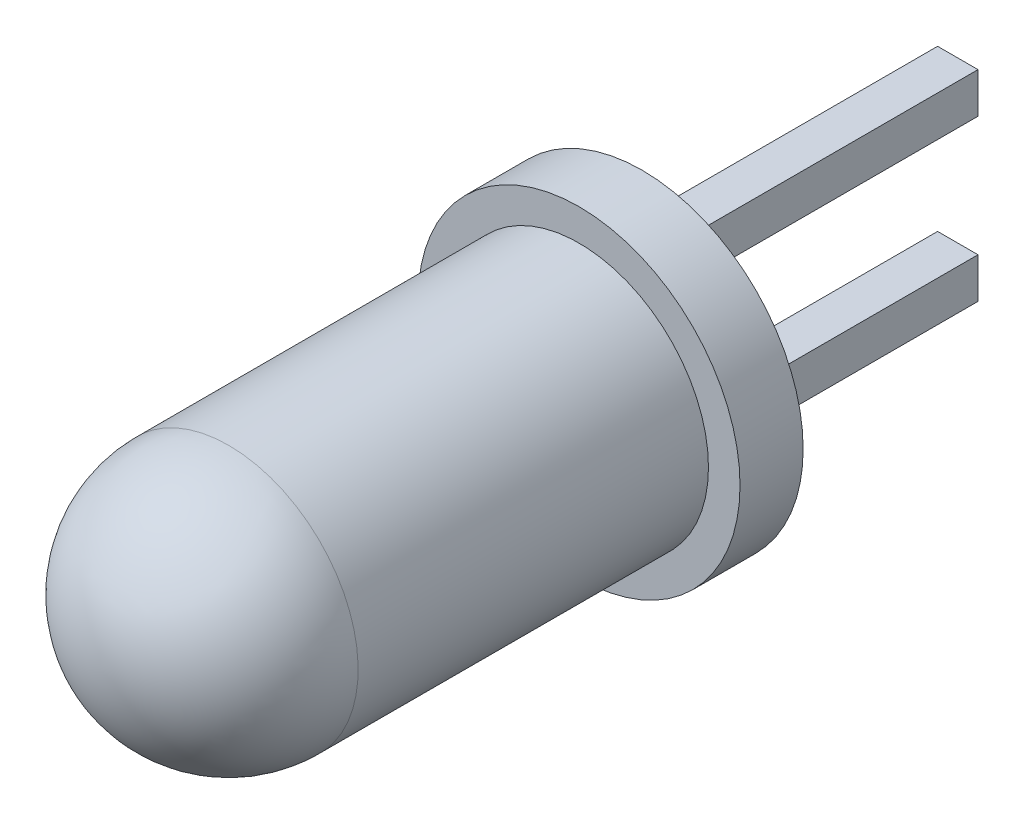
from build123d import *

# Parameters (mm, degrees)
SKETCH3_W           = 0.64
SKETCH3_H           = 0.64
BOSS_EXTRUDE1_DEPTH = 5


with BuildPart() as part:
    # Sketch2 → Base-Revolve (revolve)
    with BuildSketch(Plane(origin=(0, 0, 0), x_dir=(0, 0, -1), z_dir=(1, 0, 0))):
        with BuildLine():
            Line((0, 0), (0, 2.55))
            Line((0, 2.55), (-1, 2.55))
            Line((-1, 2.55), (-1, 2.05))
            Line((-1, 2.05), (-6.55, 2.05))
            ThreePointArc((-6.55, 2.05), (-7.999568901, 1.449568901), (-8.6, 0))
            Line((-8.6, 0), (0, 0))
        make_face()
    revolve(axis=Axis((0, 0, 0), (0, 0, 1)))

    # Sketch3 → Boss-Extrude1 (add)
    with BuildSketch(Plane(origin=(0, 0, 0), x_dir=(-1, 0, 0), z_dir=(0, 0, -1))):
        with Locations((0, 1.27)):
            Rectangle(SKETCH3_W, SKETCH3_H)
        with Locations((0, -1.27)):
            Rectangle(SKETCH3_W, SKETCH3_H)
    extrude(amount=BOSS_EXTRUDE1_DEPTH)


solid = part.part
